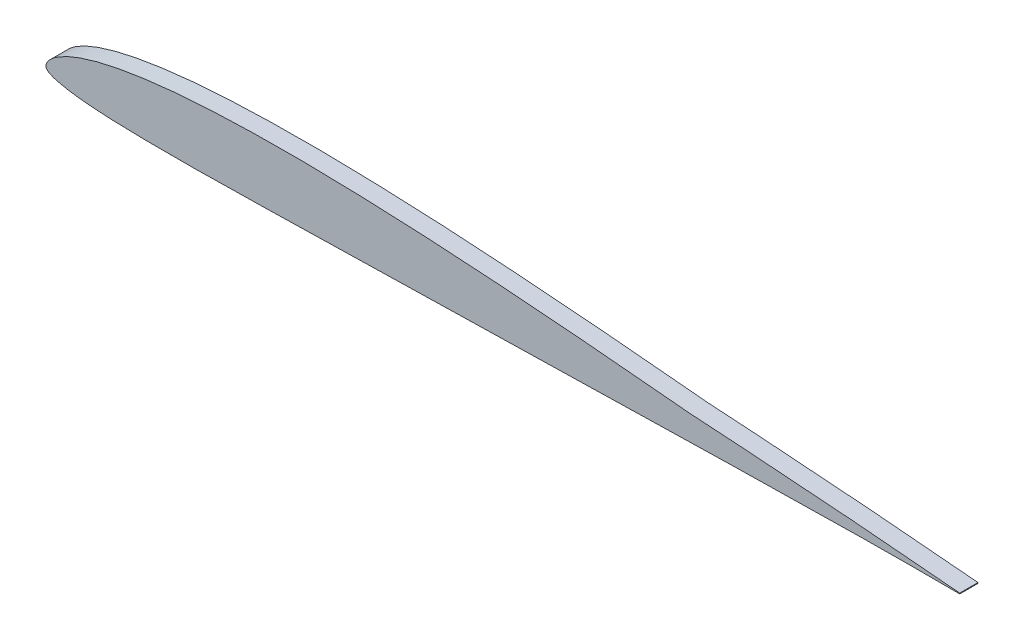
from build123d import *

# Parameters (mm, degrees)
BOSS_EXTRUDE1_DEPTH = 1.27


with BuildPart() as part:
    # Sketch2 → Boss-Extrude1 (new body, symmetric)
    with BuildSketch(Plane.XY):
        with BuildLine():
            Line((127, 0.053594), (127, -0.053594))
            add(Edge.make_bspline(
                [(127, 0.053594), (126.753194187, 0.0760877), (126.00456669, 0.144317059), (124.687918153, 0.26566799), (123.038030908, 0.409881649), (121.307814074, 0.562155781), (119.56263313, 0.715397667), (117.812451704, 0.862564502), (116.060214863, 1.009636724), (114.306556412, 1.15328943), (112.552387701, 1.2954065), (110.798143323, 1.434426003), (109.044365051, 1.569754719), (107.291127286, 1.704537205), (105.538591662, 1.83509141), (103.786392409, 1.964192438), (102.035125629, 2.09083844), (100.284111127, 2.213966217), (98.533897673, 2.336442107), (96.783942419, 2.455531649), (95.034673331, 2.572302888), (93.285592827, 2.687141326), (91.667333214, 2.791597652), (90.409246871, 2.86960854), (89.623239279, 2.921474225), (89.178221792, 2.944143026), (88.736217458, 2.991519492), (87.806500923, 3.077809397), (86.389824841, 3.21548482), (84.900074515, 3.35447567), (83.568446207, 3.477961158), (82.375283312, 3.587920635), (80.880163534, 3.723626147), (79.133561009, 3.880226285), (77.350706131, 4.036649252), (75.57251636, 4.189768369), (73.896258707, 4.331453772), (72.247372758, 4.468190396), (70.810741479, 4.584528401), (69.625039724, 4.678864068), (68.320779781, 4.781533777), (66.809591419, 4.897081839), (65.051660571, 5.027943928), (63.29489006, 5.154836731), (60.953639975, 5.317587866), (58.612649049, 5.470985337), (56.272130878, 5.614205871), (54.517155472, 5.715925242), (52.17781775, 5.84388823), (49.83871845, 5.959559707), (47.499751836, 6.061666427), (45.746142499, 6.131533932), (43.99292996, 6.19316573), (42.240233788, 6.246996168), (40.488296074, 6.292392907), (38.737205548, 6.329056298), (36.986991272, 6.355670586), (35.237667832, 6.37260324), (33.489390788, 6.378111917), (31.742631161, 6.371924362), (29.997598516, 6.353106175), (28.254705362, 6.321034192), (26.514212819, 6.273959582), (24.776789822, 6.210936383), (23.043308585, 6.130697271), (21.314341904, 6.031175464), (19.591301924, 5.911384312), (17.875349563, 5.768217119), (16.168057976, 5.600170111), (14.472222252, 5.403361178), (12.790310639, 5.17550056), (11.127244451, 4.911893185), (9.487723542, 4.607203654), (7.881002216, 4.255424938), (6.321671242, 3.849192622), (4.838377158, 3.3853758), (3.4861692, 2.868431212), (2.344289839, 2.326290026), (1.473834041, 1.805034205), (0.873330801, 1.3482402), (0.483486895, 0.969607531), (0.235533738, 0.65562371), (0.085352034, 0.388606743), (0.009278126, 0.159258483), (-0.008212661, -0.042739441), (0.035433453, -0.233172338), (0.160769969, -0.416078939), (0.381844651, -0.578881525), (0.702443674, -0.744483608), (1.173773308, -0.923146696), (1.873336967, -1.121921903), (2.863352071, -1.325051442), (4.13416469, -1.514401551), (5.608772302, -1.671307235), (7.196892742, -1.792063517), (8.842033522, -1.881526049), (10.518101058, -1.94501169), (12.213760951, -1.988134813), (13.923057968, -2.015603352), (15.642305988, -2.030559213), (17.369324492, -2.03524324), (19.102259281, -2.030376268), (20.840178662, -2.017661001), (22.581905241, -1.998654224), (24.327094149, -1.973870035), (26.075373333, -1.944918864), (27.827248085, -1.912478734), (29.582726999, -1.877605576), (31.342000464, -1.840019272), (33.105065172, -1.801905031), (34.872261178, -1.761818771), (36.643314641, -1.721008732), (39.010854937, -1.665986942), (41.381807413, -1.609827319), (43.75560561, -1.553814319), (45.538561311, -1.511849459), (47.323033301, -1.46955775), (49.109250939, -1.427647022), (50.897446959, -1.385341566), (52.686668924, -1.343543423), (54.475758497, -1.30172749), (56.263619605, -1.260128912), (58.050348911, -1.219185975), (59.835998699, -1.177618913), (61.620483593, -1.137195049), (63.403644196, -1.096671294), (65.185629967, -1.056824853), (66.966841129, -1.016671311), (68.474715573, -0.983169692), (70.232782952, -0.944255707), (71.967211638, -0.905142513), (73.938977171, -0.86146372), (75.655131362, -0.823379675), (77.377116294, -0.784663907), (79.116977386, -0.746124442), (80.674292865, -0.711626582), (82.037721658, -0.681571553), (83.189530456, -0.656499215), (84.514431826, -0.627441819), (86.036149029, -0.594655294), (87.442288836, -0.564185094), (88.395472904, -0.544103578), (88.857745192, -0.53403148), (89.250570862, -0.526534286), (90.047987318, -0.508966656), (91.345085306, -0.481934603), (93.049931567, -0.446327812), (94.810657831, -0.41008595), (96.570459821, -0.374659881), (98.329784851, -0.339179197), (100.089333738, -0.304693935), (101.849164273, -0.270047735), (103.609427245, -0.236629083), (105.36992798, -0.203795698), (107.130919286, -0.174231328), (109.479457843, -0.136894236), (111.828794682, -0.105060522), (114.178357376, -0.07832436), (115.941250848, -0.062296483), (117.704221306, -0.048903014), (119.467622017, -0.040031049), (121.230174814, -0.035574086), (122.981472146, -0.034856596), (124.653848233, -0.041755393), (125.989887143, -0.047834399), (126.749429154, -0.052165261), (127, -0.053594)],
                knots=[0, 0, 0, 0, 0.002900997, 0.008799492, 0.015477521, 0.022287594, 0.029131106, 0.035984573, 0.042846882, 0.049714298, 0.05658103, 0.063447841, 0.070313229, 0.077171168, 0.084031174, 0.090884627, 0.097737396, 0.104584409, 0.111431996, 0.118274877, 0.125116136, 0.131953905, 0.138793041, 0.144098463, 0.146708547, 0.148014316, 0.149313147, 0.151910856, 0.158944662, 0.165973894, 0.169425198, 0.174599098, 0.179999827, 0.186998484, 0.195126222, 0.200949457, 0.207890371, 0.214817866, 0.220316978, 0.224762114, 0.228741132, 0.235631413, 0.242503169, 0.249375779, 0.256249105, 0.269975124, 0.276837254, 0.283697593, 0.290552693, 0.304261607, 0.311111523, 0.317957829, 0.324804965, 0.331646618, 0.338483878, 0.345319338, 0.352148661, 0.358973535, 0.365797142, 0.372613328, 0.379420455, 0.386224885, 0.393018255, 0.399801226, 0.406575621, 0.413331117, 0.420072962, 0.426793048, 0.433486562, 0.440153627, 0.446776036, 0.453352888, 0.45986197, 0.466293612, 0.472602109, 0.478718386, 0.484476601, 0.489534097, 0.493495639, 0.496331131, 0.498346313, 0.499841011, 0.500999224, 0.501914653, 0.502649229, 0.503345398, 0.504157805, 0.50518516, 0.50652574, 0.508375842, 0.511073875, 0.515031357, 0.520196697, 0.526108615, 0.532386125, 0.538838474, 0.545393385, 0.552018993, 0.558693317, 0.565404176, 0.572144526, 0.578909155, 0.585689295, 0.592488493, 0.599298368, 0.606119897, 0.612956027, 0.619808707, 0.626672964, 0.633554162, 0.640451345, 0.647364459, 0.654290996, 0.668172424, 0.675125782, 0.68208558, 0.689048858, 0.69602005, 0.703000172, 0.70998671, 0.716969769, 0.723948347, 0.730920449, 0.737890086, 0.744856199, 0.751814362, 0.758768528, 0.765720713, 0.772669892, 0.776423534, 0.786305074, 0.792977667, 0.799509992, 0.806398719, 0.813139713, 0.819881191, 0.82463258, 0.829103409, 0.833367055, 0.84014514, 0.846920231, 0.849830697, 0.851305256, 0.85233271, 0.85442981, 0.86064179, 0.867519383, 0.874390494, 0.8812566, 0.888123181, 0.894988723, 0.901857217, 0.908727131, 0.915597457, 0.922468599, 0.929343575, 0.943092095, 0.949971604, 0.956848493, 0.963728748, 0.970608901, 0.977490477, 0.984360632, 0.991108924, 0.997066858, 1, 1, 1, 1], degree=3))
        make_face()
    extrude(amount=BOSS_EXTRUDE1_DEPTH, both=True)


solid = part.part
